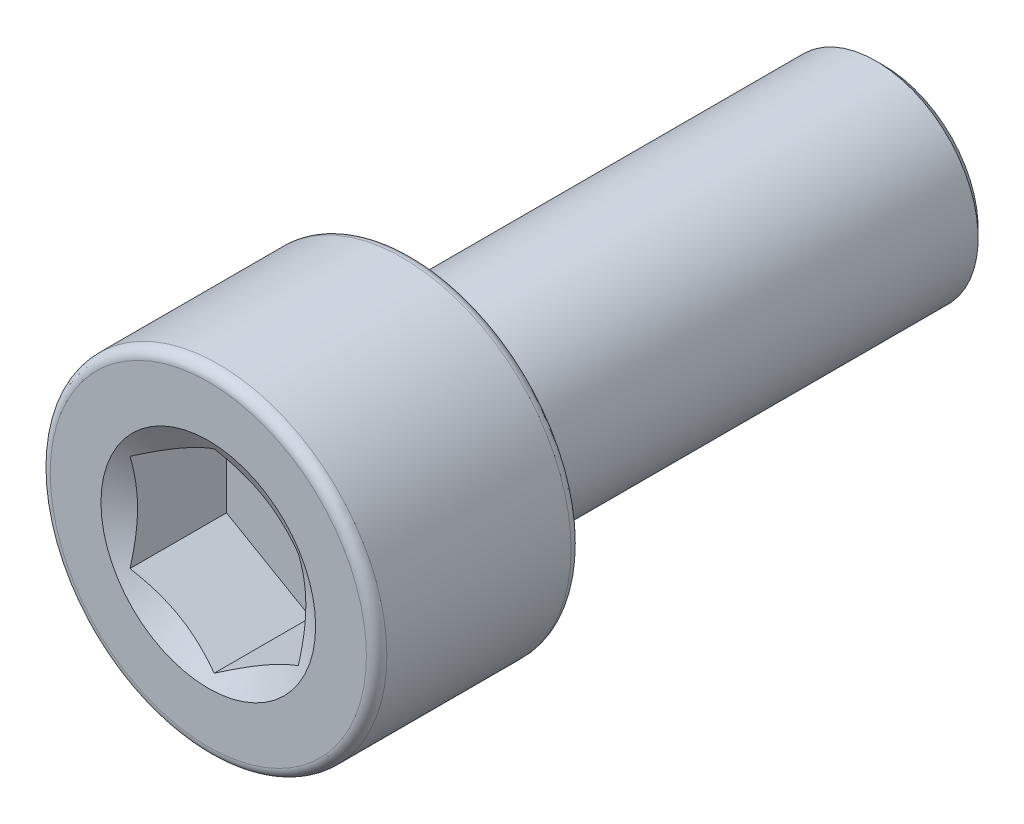
from build123d import *

# Parameters (mm, degrees)
CUT_EXTRUDE1_START = 7.96925
CUT_EXTRUDE1_DEPTH = 2.413


with BuildPart() as part:
    # Sketch2 → Revolve1 (revolve)
    with BuildSketch(Plane(origin=(0, 0, 0), x_dir=(0, 0, -1), z_dir=(1, 0, 0)), mode=Mode.PRIVATE) as revolve1_sk:
        with BuildLine():
            Line((7.96925, 0), (7.96925, 2.2145625))
            Line((7.96925, 2.2145625), (7.7708125, 2.413))
            Line((7.7708125, 2.413), (-3.14325, 2.413))
            Line((-3.14325, 2.413), (-3.14325, 3.72745))
            ThreePointArc((-3.14325, 3.72745), (-3.213925134, 3.898074866), (-3.38455, 3.96875))
            Line((-3.38455, 3.96875), (-7.72795, 3.96875))
            ThreePointArc((-7.72795, 3.96875), (-7.898574866, 3.898074866), (-7.96925, 3.72745))
            Line((-7.96925, 3.72745), (-7.96925, 0))
            Line((-7.96925, 0), (7.96925, 0))
        make_face()
    revolve(revolve1_sk.sketch.rotate(Axis((0, 0, -7.96925), (0, 0, 1)), 90), axis=Axis((0, 0, -7.96925), (0, 0, 1)))

    # Sketch3 → Cut-Extrude1 (cut)
    with BuildSketch(Plane.XY.offset(CUT_EXTRUDE1_START)):
        Polygon((-1.984375, 1.14567944), (-1.984375, -1.14567944), (0, -2.291358881), (1.984375, -1.14567944), (1.984375, 1.14567944), (0, 2.291358881), align=None)
    extrude(amount=-CUT_EXTRUDE1_DEPTH, mode=Mode.SUBTRACT)

    # Cut-Extrude2 cone 1 section (through the dimple's axis) → Cut-Extrude2 (revolve, cut)
    with BuildSketch(Plane(origin=(0, 0, 7.96925), x_dir=(0, -1, 0), z_dir=(1, 0, 0))):
        Polygon((0, 0), (2.530707401, 0), (0, 1.461104599), align=None)
    revolve(axis=Axis((0, 0, 7.96925), (0, 0, -1)), mode=Mode.SUBTRACT)


solid = part.part
